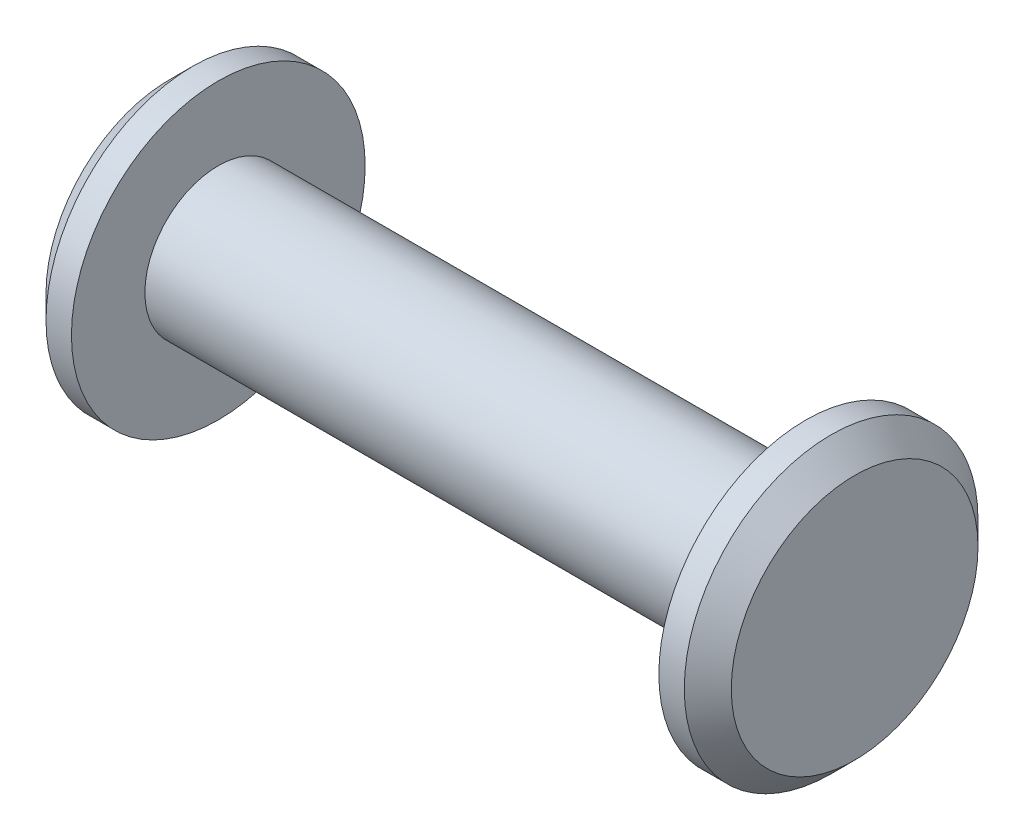
from build123d import *

# Parameters (mm, degrees)
CHAMFER1_SIZE = 0.762


with BuildPart() as part:
    # Sketch1 → Base-Revolve (revolve)
    with BuildSketch(Plane.XY):
        Polygon((11.1125, 0), (11.1125, 4.7625), (9.525, 4.7625), (9.525, 2.38125), (-9.525, 2.38125), (-9.525, 4.7625), (-11.1125, 4.7625), (-11.1125, 0), align=None)
    revolve(axis=Axis((0, 0, 0), (1, 0, 0)))

    # Chamfer1
    chamfer1_edges = [part.edges().sort_by_distance(p)[0] for p in [
        (11.1125, -4.7625, 0),
        (-11.1125, -4.7625, 0),
    ]]
    chamfer(chamfer1_edges, length=CHAMFER1_SIZE)


solid = part.part
